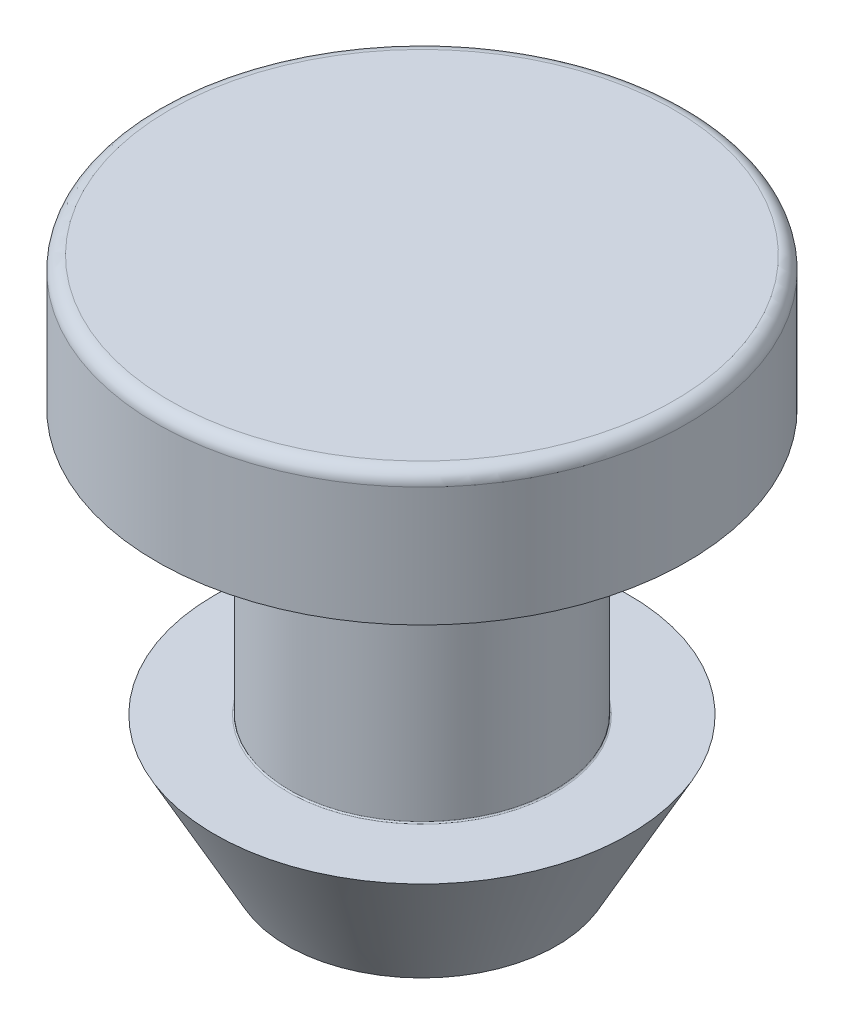
from build123d import *

# Parameters (mm, degrees)
SKETCH3_R          = 0.347265625
CUT_EXTRUDE1_DEPTH = 0.3175


with BuildPart() as part:
    # Sketch2 → Revolve1 (revolve)
    with BuildSketch(Plane.XY):
        with BuildLine():
            Line((0, 3.175), (0, -9.525))
            Line((0, -9.525), (3.224609375, -9.525))
            Line((3.224609375, -9.525), (4.9609375, -6.35))
            Line((4.9609375, -6.35), (3.20675, -6.35))
            ThreePointArc((3.20675, -6.35), (3.18429936, -6.34070064), (3.175, -6.31825))
            Line((3.175, -6.31825), (3.175, -0.03175))
            ThreePointArc((3.175, -0.03175), (3.18429936, -0.00929936), (3.20675, 0))
            Line((3.20675, 0), (6.35, 0))
            Line((6.35, 0), (6.35, 2.8575))
            ThreePointArc((6.35, 2.8575), (6.257006403, 3.082006403), (6.0325, 3.175))
            Line((6.0325, 3.175), (0, 3.175))
        make_face()
    revolve(axis=Axis((0, 3.175, 0), (0, -1, 0)))

    # Sketch3 → Cut-Extrude1 (cut)
    with BuildSketch(Plane.XZ.offset(9.525)):
        with Locations((0, 2.28203125)):
            Circle(SKETCH3_R)
        with Locations((1.976297035, -1.141015625)):
            Circle(SKETCH3_R)
        with Locations((-1.976297035, -1.141015625)):
            Circle(SKETCH3_R)
    extrude(amount=-CUT_EXTRUDE1_DEPTH, mode=Mode.SUBTRACT)


solid = part.part
